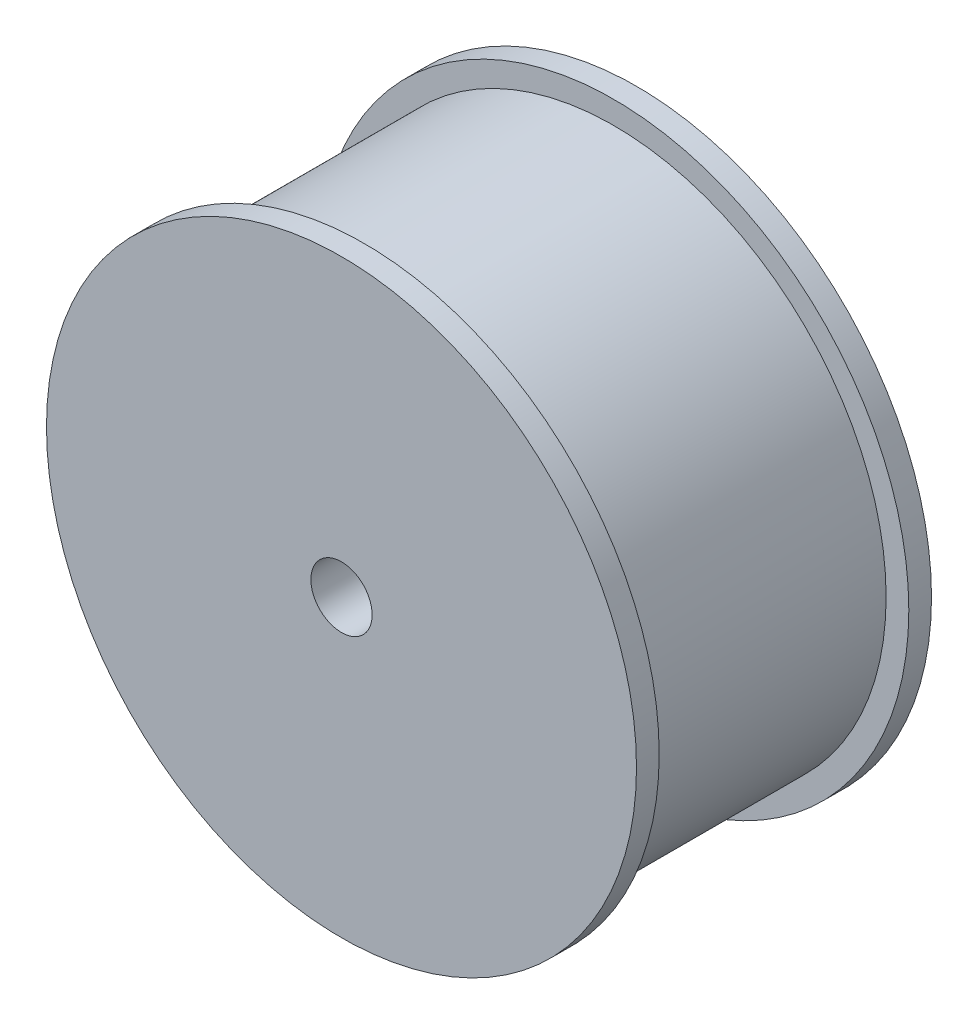
from build123d import *

# Parameters (mm, degrees)
SKETCH1_R           = 24
BOSS_EXTRUDE1_DEPTH = 11
SKETCH3_R           = 26
BOSS_EXTRUDE2_DEPTH = 2
SKETCH5_R           = 2.7
CUT_EXTRUDE1_DEPTH  = 46.033320997
SKETCH6_R           = 6.5
SKETCH6_R_2         = 2.7
BOSS_EXTRUDE3_DEPTH = 4


with BuildPart() as part:
    # Sketch1 → Boss-Extrude1 (new, symmetric)
    with BuildSketch(Plane.XY):
        Circle(SKETCH1_R)
    extrude(amount=BOSS_EXTRUDE1_DEPTH, both=True)

    # Sketch3 → Boss-Extrude2 (add)
    with BuildSketch(Plane.XY.offset(11)):
        Circle(SKETCH3_R)
    boss_extrude2 = extrude(amount=BOSS_EXTRUDE2_DEPTH)

    # Mirror1: Boss-Extrude2 across plane
    add(boss_extrude2.mirror(Plane.XY))

    # Sketch5 → Cut-Extrude1 (cut, through all)
    with BuildSketch(Plane.XY.offset(13)):
        Circle(SKETCH5_R)
    extrude(amount=-CUT_EXTRUDE1_DEPTH, mode=Mode.SUBTRACT)

    # Sketch6 → Boss-Extrude3 (add)
    with BuildSketch(Plane(origin=(0, 0, -13), x_dir=(-1, 0, 0), z_dir=(0, 0, -1))):
        Circle(SKETCH6_R)
        with Locations(Location((0, 0, 0), (0, 0, 180))):
            Circle(SKETCH6_R_2, mode=Mode.SUBTRACT)
    extrude(amount=BOSS_EXTRUDE3_DEPTH)


solid = part.part
